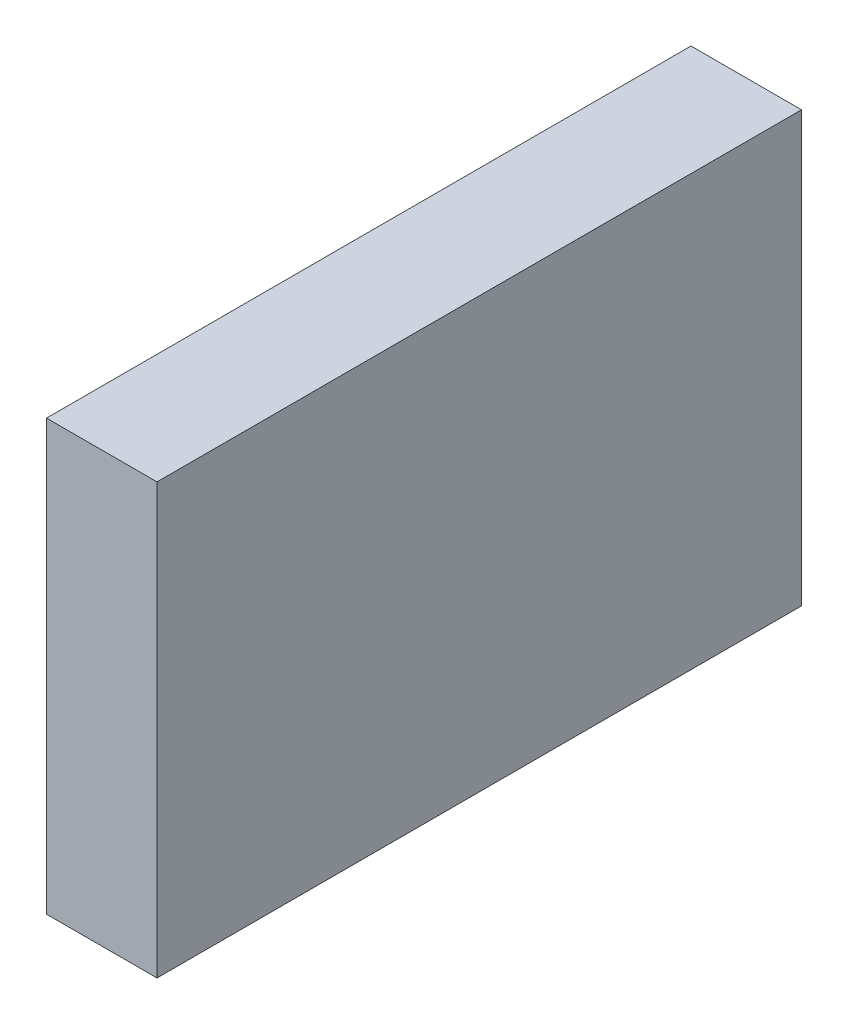
from build123d import *

# Parameters (mm, degrees)
SKETCH1_W           = 3.6
SKETCH1_H           = 21
BOSS_EXTRUDE1_DEPTH = 14


with BuildPart() as part:
    # Sketch1 → Boss-Extrude1 (new body)
    with BuildSketch(Plane(origin=(0, 0, 0), x_dir=(1, 0, 0), z_dir=(0, 1, 0))):
        with Locations((1.8, 10.5)):
            Rectangle(SKETCH1_W, SKETCH1_H)
    extrude(amount=BOSS_EXTRUDE1_DEPTH)


solid = part.part
